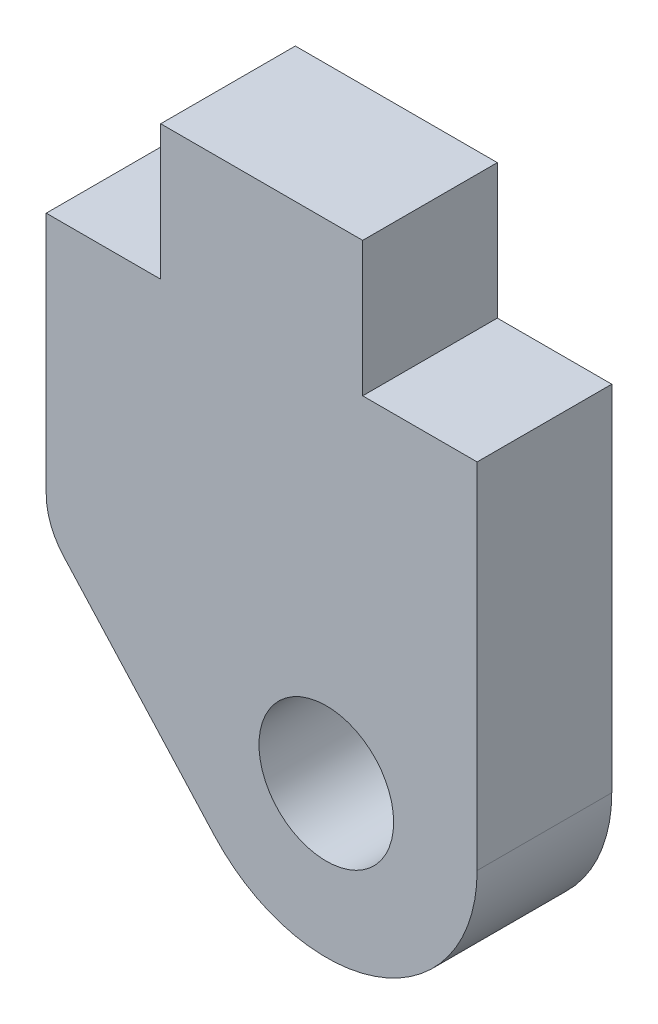
from build123d import *

# Parameters (mm, degrees)
SKETCH1_R           = 1.5875
BOSS_EXTRUDE1_DEPTH = 1.5875


with BuildPart() as part:
    # Sketch1 → Boss-Extrude1 (new body, symmetric)
    with BuildSketch(Plane.XY):
        with BuildLine():
            Line((-5.08, 0), (-5.08, -5.737908239))
            ThreePointArc((-5.08, -5.737908239), (-4.973712071, -6.309018604), (-4.669080882, -6.803653836))
            Line((-4.669080882, -6.803653836), (-1.111541176, -10.731170137))
            ThreePointArc((-1.111541176, -10.731170137), (2.803287219, -11.66181504), (5.08, -8.3439))
            Line((5.08, -8.3439), (5.08, 0))
            Line((5.08, 0), (2.38125, 0))
            Line((2.38125, 0), (2.38125, 3.175))
            Line((2.38125, 3.175), (-2.38125, 3.175))
            Line((-2.38125, 3.175), (-2.38125, 0))
            Line((-2.38125, 0), (-5.08, 0))
        make_face()
        with Locations((1.524, -8.3439)):
            Circle(SKETCH1_R, mode=Mode.SUBTRACT)
    extrude(amount=BOSS_EXTRUDE1_DEPTH, both=True)


solid = part.part
